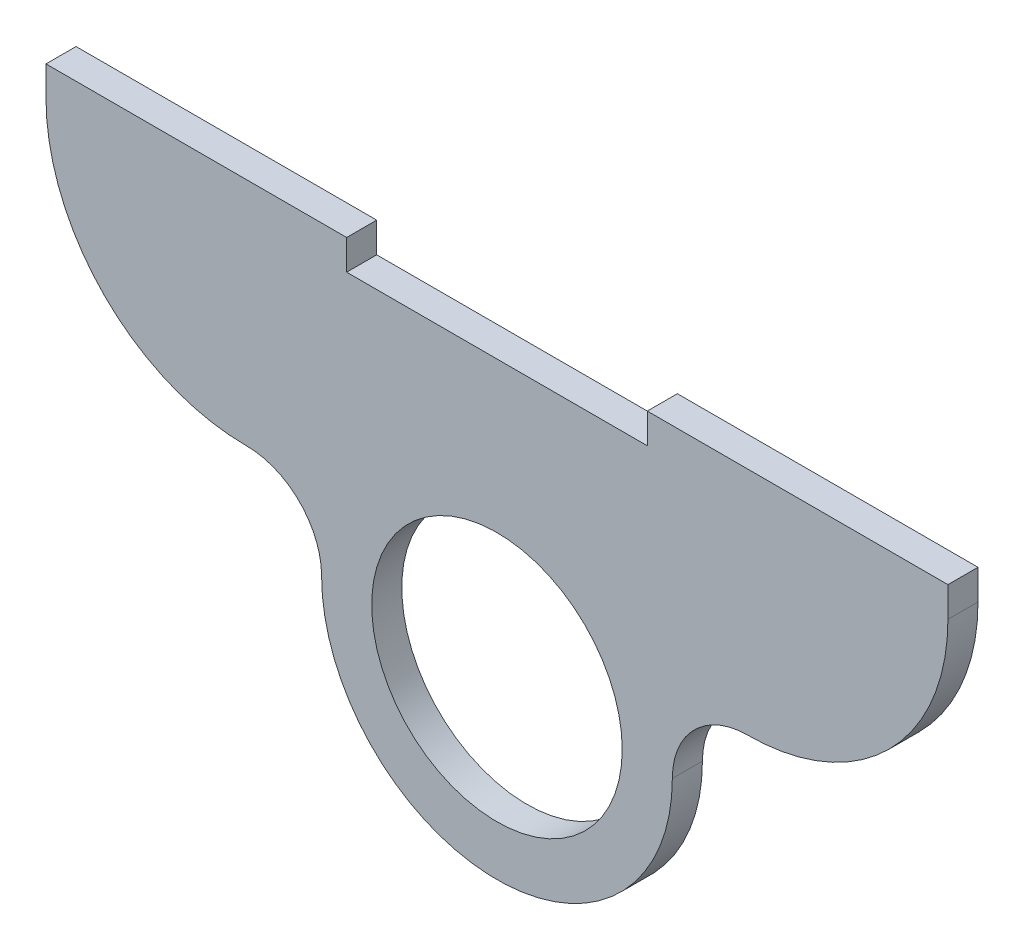
from build123d import *

# Parameters (mm, degrees)
SKETCH1_R           = 12.5
BOSS_EXTRUDE1_DEPTH = 3


with BuildPart() as part:
    # Sketch1 → Boss-Extrude1 (new body)
    with BuildSketch(Plane.XY):
        with BuildLine():
            Line((-15, 27.5), (15, 27.5))
            Line((15, 27.5), (15, 30.5))
            Line((15, 30.5), (45, 30.5))
            Line((45, 30.5), (45, 27.5))
            ThreePointArc((45, 27.5), (39.142135624, 13.357864376), (25, 7.5))
            ThreePointArc((25, 7.5), (19.696699141, 5.303300859), (17.5, 0))
            ThreePointArc((17.5, 0), (0, -17.5), (-17.5, 0))
            ThreePointArc((-17.5, 0), (-19.696699141, 5.303300859), (-25, 7.5))
            ThreePointArc((-25, 7.5), (-39.142135624, 13.357864376), (-45, 27.5))
            Line((-45, 27.5), (-45, 30.5))
            Line((-45, 30.5), (-15, 30.5))
            Line((-15, 30.5), (-15, 27.5))
        make_face()
        Circle(SKETCH1_R, mode=Mode.SUBTRACT)
    extrude(amount=BOSS_EXTRUDE1_DEPTH)


solid = part.part
